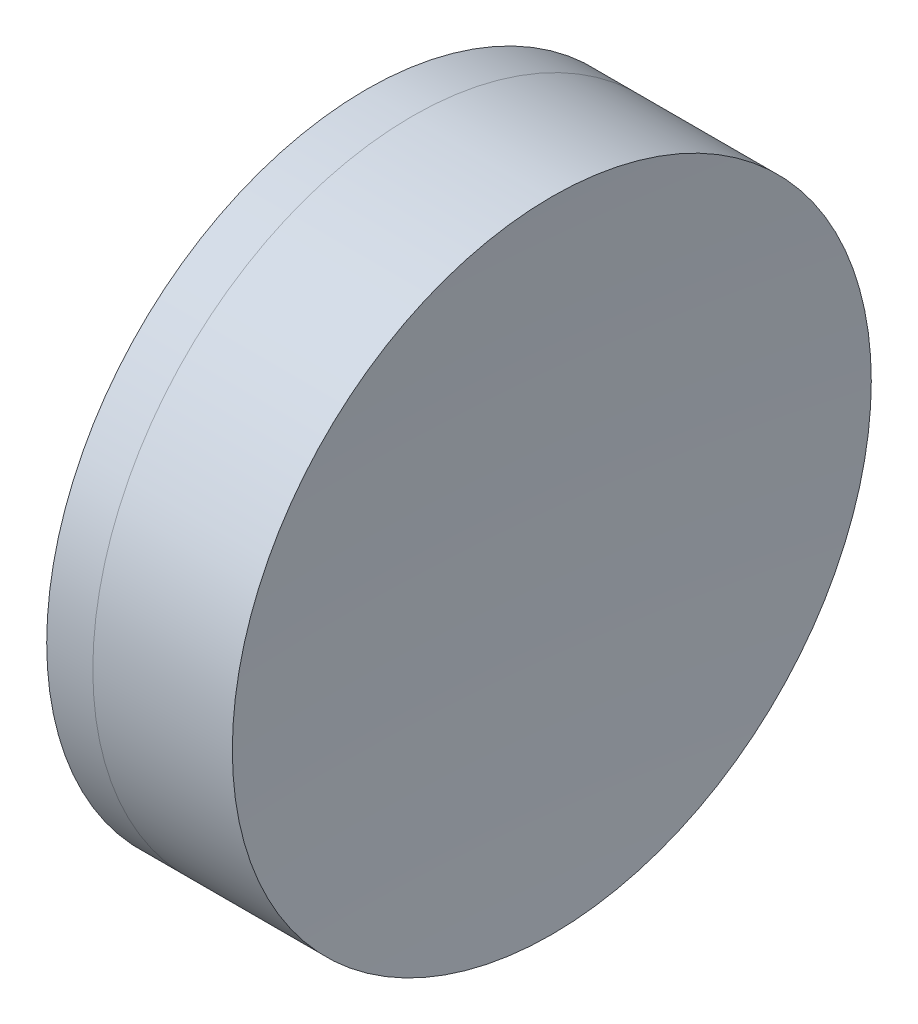
from build123d import *


with BuildPart() as part:
    # 草图1 one side → 旋转1 (revolve)
    with BuildSketch(Plane(origin=(0, 0, 0), x_dir=(1, 0, 0), z_dir=(0, 1, 0)), mode=Mode.PRIVATE) as revolve_1_sk:
        with BuildLine():
            ThreePointArc((35.795615005, 12.7), (32.939366663, 6.633376716), (31.959373797, 0))
            Line((31.959373797, 0), (40.959373797, 0))
            ThreePointArc((40.959373797, 0), (40.11293141, 6.564708163), (37.628972463, 12.7))
            Line((37.628972463, 12.7), (35.795615005, 12.7))
        make_face()
    revolve(revolve_1_sk.sketch.rotate(Axis((-0.816062176, 0, 0), (1, 0, 0)), 180), axis=Axis((-0.816062176, 0, 0), (1, 0, 0)))  # turned: the seam where the file's is


with BuildPart() as body_2:
    # 草图2 one side → 旋转2 (revolve)
    with BuildSketch(Plane(origin=(0, 0, 0), x_dir=(1, 0, 0), z_dir=(0, 1, 0)), mode=Mode.PRIVATE) as revolve_2_sk:
        with BuildLine():
            Line((43.174358408, 12.7), (37.628972463, 12.7))
            ThreePointArc((37.628972463, 12.7), (40.11293141, 6.564708163), (40.959373797, 0))
            Line((40.959373797, 0), (42.759373797, 0))
            ThreePointArc((42.759373797, 0), (42.863147628, 6.3533891), (43.174358408, 12.7))
        make_face()
    revolve(revolve_2_sk.sketch.rotate(Axis((-0.551919993, 0, 0), (1, 0, 0)), 180), axis=Axis((-0.551919993, 0, 0), (1, 0, 0)))  # turned: the seam where the file's is


solid = Compound([part.part, body_2.part])
